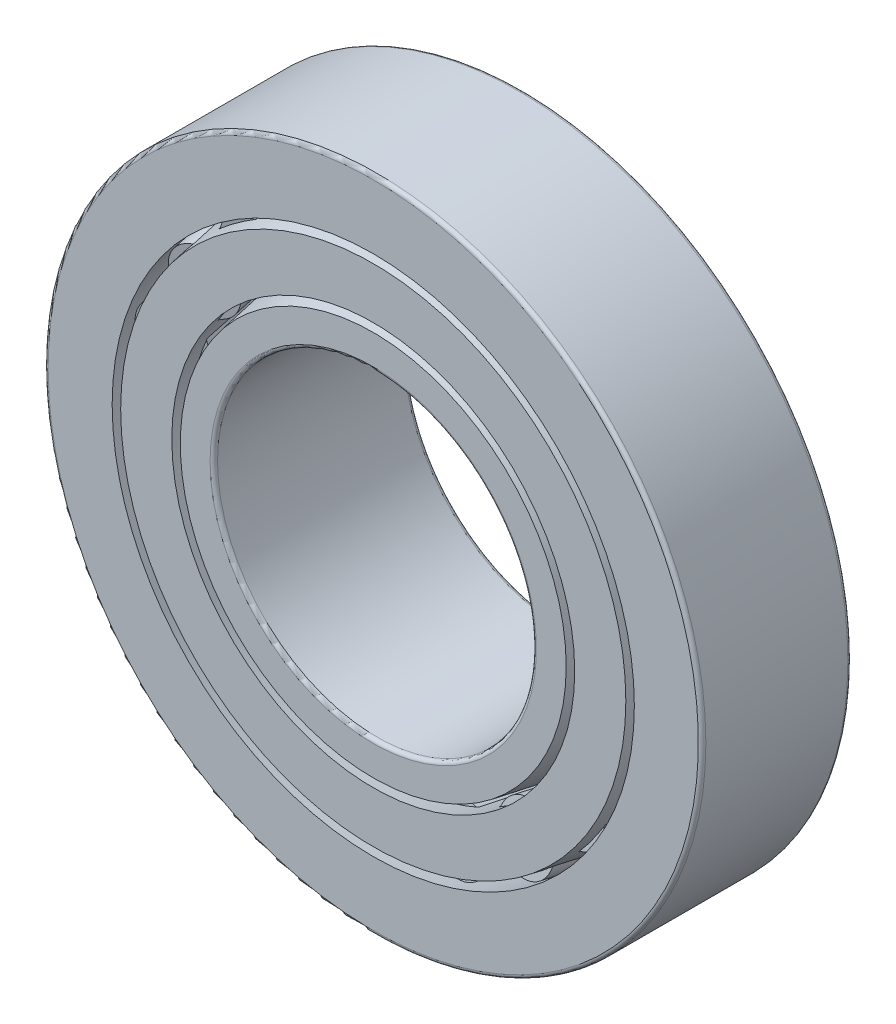
from build123d import *

# Parameters (mm, degrees)
CIRPATTERN1_COUNT = 20
CIRPATTERN2_COUNT = 20
FILLET1_R         = 0.5953125
FILLET2_R         = 0.5953125


with BuildPart() as part:
    # Sketch1 → Revolve1 (revolve)
    with BuildSketch(Plane(origin=(0, 0, 0), x_dir=(0, 0, -1), z_dir=(1, 0, 0))):
        Polygon((-15.478125, 52.3875), (8.334375, 52.3875), (8.334375, 45.791286228), (-15.478125, 41.5925), align=None)
    revolve(axis=Axis((0, 0, 15.478125), (0, 0, -1)))

    # Fillet1
    fillet1_edges = [part.edges().sort_by_distance(p)[0] for p in [
        (0, -52.3875, -8.334375),
        (0, -52.3875, 15.478125),
    ]]
    fillet(fillet1_edges, radius=FILLET1_R)


with BuildPart() as body_2:
    # Sketch5 → Revolve4 (revolve)
    with BuildSketch(Plane(origin=(0, 0, 0), x_dir=(0, 0, -1), z_dir=(1, 0, 0))):
        Polygon((15.478125, 36.195), (-15.478125, 30.736577903), (-15.478125, 25.4), (15.478125, 25.4), align=None)
    revolve(axis=Axis((0, 0, 15.478125), (0, 0, -1)))

    # Fillet2
    fillet2_edges = [body_2.edges().sort_by_distance(p)[0] for p in [
        (0, -25.4, -15.478125),
        (0, -25.4, 15.478125),
    ]]
    fillet(fillet2_edges, radius=FILLET2_R)


with BuildPart() as body_3:
    # Sketch2 → Revolve2 (revolve)
    with BuildSketch(Plane(origin=(0, 0, 0), x_dir=(0, 0, -1), z_dir=(1, 0, 0))):
        Polygon((-15.478125, 40.235509738), (-15.478125, 32.093568166), (8.334375, 36.292354394), (14.452315998, 37.371112458), (13.059961986, 45.267544451), (8.334375, 44.434295966), align=None)
    revolve(axis=Axis((0, 0, 15.478125), (0, 0, -1)))

    # Sketch3 → Cut-Revolve1 (revolve, cut)
    with BuildSketch(Plane(origin=(0, 0, 0), x_dir=(0, 0, -1), z_dir=(1, 0, 0))):
        Polygon((-12.693416976, 36.65555811), (-13.621652984, 41.919846105), (7.406138992, 45.627613175), (8.334375, 40.36332518), align=None)
    cut_revolve1 = revolve(axis=Axis((0, 36.164538952, 15.478125), (0, 0.17364817766692528, -0.984807753012209)), mode=Mode.SUBTRACT)

    # CirPattern1: Cut-Revolve1 ×20 about axis
    cirpattern1_axis = Axis((0, 0, -15.478125), (0, 0, 1))
    for i in range(1, CIRPATTERN1_COUNT):
        add(cut_revolve1.rotate(cirpattern1_axis, i * 360 / CIRPATTERN1_COUNT), mode=Mode.SUBTRACT)


with BuildPart() as body_4:
    # Sketch4 → Revolve3 (revolve)
    with BuildSketch(Plane(origin=(0, 0, 0), x_dir=(0, 0, -1), z_dir=(1, 0, 0))):
        Polygon((-13.577546347, 41.669704936), (7.450245629, 45.377472006), (8.334375, 40.36332518), (-12.693416976, 36.65555811), align=None)
    revolve(axis=Axis((0, 36.164538952, 15.478125), (0, 0.17364817766692528, -0.984807753012209)))


with BuildPart() as cirpattern2_1:
    # CirPattern2: pattern copy
    add(body_4.part.rotate(Axis((0, 0, -15.478125), (0, 0, 1)), 1 * 360 / CIRPATTERN2_COUNT))


with BuildPart() as cirpattern2_2:
    # CirPattern2: pattern copy
    add(body_4.part.rotate(Axis((0, 0, -15.478125), (0, 0, 1)), 2 * 360 / CIRPATTERN2_COUNT))


with BuildPart() as cirpattern2_3:
    # CirPattern2: pattern copy
    add(body_4.part.rotate(Axis((0, 0, -15.478125), (0, 0, 1)), 3 * 360 / CIRPATTERN2_COUNT))


with BuildPart() as cirpattern2_4:
    # CirPattern2: pattern copy
    add(body_4.part.rotate(Axis((0, 0, -15.478125), (0, 0, 1)), 4 * 360 / CIRPATTERN2_COUNT))


with BuildPart() as cirpattern2_5:
    # CirPattern2: pattern copy
    add(body_4.part.rotate(Axis((0, 0, -15.478125), (0, 0, 1)), 5 * 360 / CIRPATTERN2_COUNT))


with BuildPart() as cirpattern2_6:
    # CirPattern2: pattern copy
    add(body_4.part.rotate(Axis((0, 0, -15.478125), (0, 0, 1)), 6 * 360 / CIRPATTERN2_COUNT))


with BuildPart() as cirpattern2_7:
    # CirPattern2: pattern copy
    add(body_4.part.rotate(Axis((0, 0, -15.478125), (0, 0, 1)), 7 * 360 / CIRPATTERN2_COUNT))


with BuildPart() as cirpattern2_8:
    # CirPattern2: pattern copy
    add(body_4.part.rotate(Axis((0, 0, -15.478125), (0, 0, 1)), 8 * 360 / CIRPATTERN2_COUNT))


with BuildPart() as cirpattern2_9:
    # CirPattern2: pattern copy
    add(body_4.part.rotate(Axis((0, 0, -15.478125), (0, 0, 1)), 9 * 360 / CIRPATTERN2_COUNT))


with BuildPart() as cirpattern2_10:
    # CirPattern2: pattern copy
    add(body_4.part.rotate(Axis((0, 0, -15.478125), (0, 0, 1)), 10 * 360 / CIRPATTERN2_COUNT))


with BuildPart() as cirpattern2_11:
    # CirPattern2: pattern copy
    add(body_4.part.rotate(Axis((0, 0, -15.478125), (0, 0, 1)), 11 * 360 / CIRPATTERN2_COUNT))


with BuildPart() as cirpattern2_12:
    # CirPattern2: pattern copy
    add(body_4.part.rotate(Axis((0, 0, -15.478125), (0, 0, 1)), 12 * 360 / CIRPATTERN2_COUNT))


with BuildPart() as cirpattern2_13:
    # CirPattern2: pattern copy
    add(body_4.part.rotate(Axis((0, 0, -15.478125), (0, 0, 1)), 13 * 360 / CIRPATTERN2_COUNT))


with BuildPart() as cirpattern2_14:
    # CirPattern2: pattern copy
    add(body_4.part.rotate(Axis((0, 0, -15.478125), (0, 0, 1)), 14 * 360 / CIRPATTERN2_COUNT))


with BuildPart() as cirpattern2_15:
    # CirPattern2: pattern copy
    add(body_4.part.rotate(Axis((0, 0, -15.478125), (0, 0, 1)), 15 * 360 / CIRPATTERN2_COUNT))


with BuildPart() as cirpattern2_16:
    # CirPattern2: pattern copy
    add(body_4.part.rotate(Axis((0, 0, -15.478125), (0, 0, 1)), 16 * 360 / CIRPATTERN2_COUNT))


with BuildPart() as cirpattern2_17:
    # CirPattern2: pattern copy
    add(body_4.part.rotate(Axis((0, 0, -15.478125), (0, 0, 1)), 17 * 360 / CIRPATTERN2_COUNT))


with BuildPart() as cirpattern2_18:
    # CirPattern2: pattern copy
    add(body_4.part.rotate(Axis((0, 0, -15.478125), (0, 0, 1)), 18 * 360 / CIRPATTERN2_COUNT))


with BuildPart() as cirpattern2_19:
    # CirPattern2: pattern copy
    add(body_4.part.rotate(Axis((0, 0, -15.478125), (0, 0, 1)), 19 * 360 / CIRPATTERN2_COUNT))


solid = Compound([part.part, body_2.part, body_3.part, body_4.part, cirpattern2_1.part, cirpattern2_2.part, cirpattern2_3.part, cirpattern2_4.part, cirpattern2_5.part, cirpattern2_6.part, cirpattern2_7.part, cirpattern2_8.part, cirpattern2_9.part, cirpattern2_10.part, cirpattern2_11.part, cirpattern2_12.part, cirpattern2_13.part, cirpattern2_14.part, cirpattern2_15.part, cirpattern2_16.part, cirpattern2_17.part, cirpattern2_18.part, cirpattern2_19.part])
